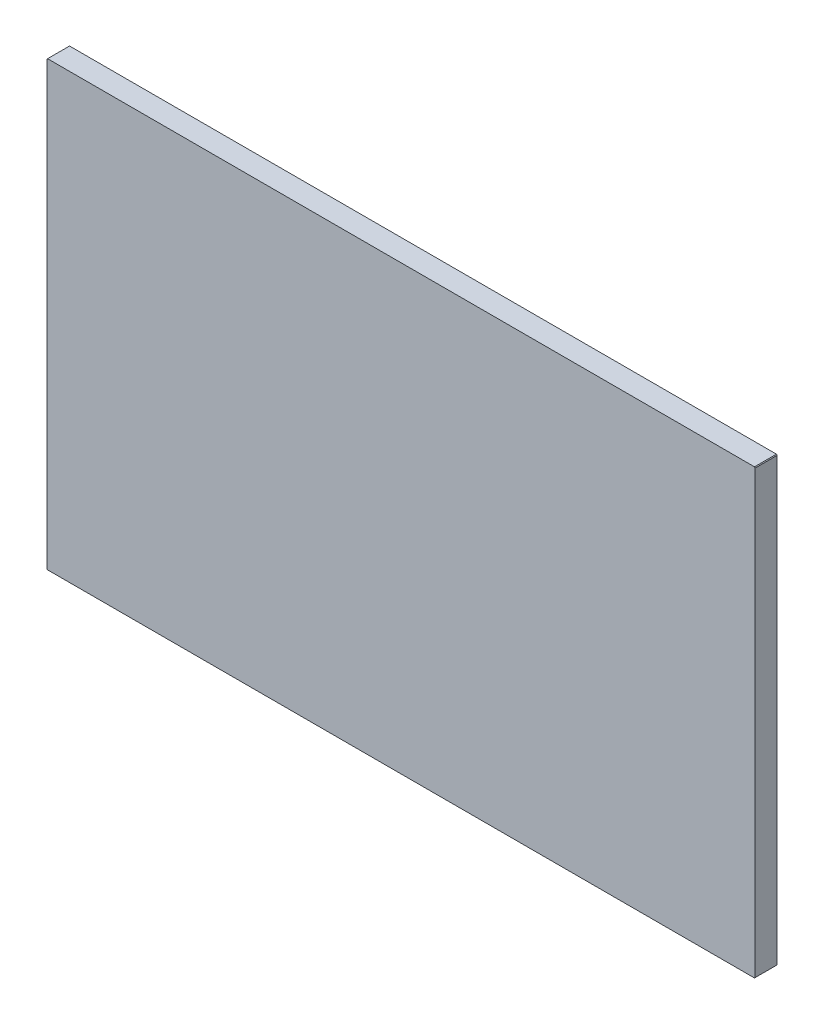
from build123d import *

# Parameters (mm, degrees)
EXTRUDE1_DEPTH = 0.7874


with BuildPart() as part:
    # Sketch1 → Extrude1 (new body)
    with BuildSketch(Plane.XY):
        Polygon((-25.3746, 15.875), (-25.4, 15.8496), (-25.4, 0.0254), (-25.3746, 0), (-0.0254, 0), (0, 0.0254), (0, 15.8496), (-0.0254, 15.875), align=None)
    extrude(amount=EXTRUDE1_DEPTH)


solid = part.part
